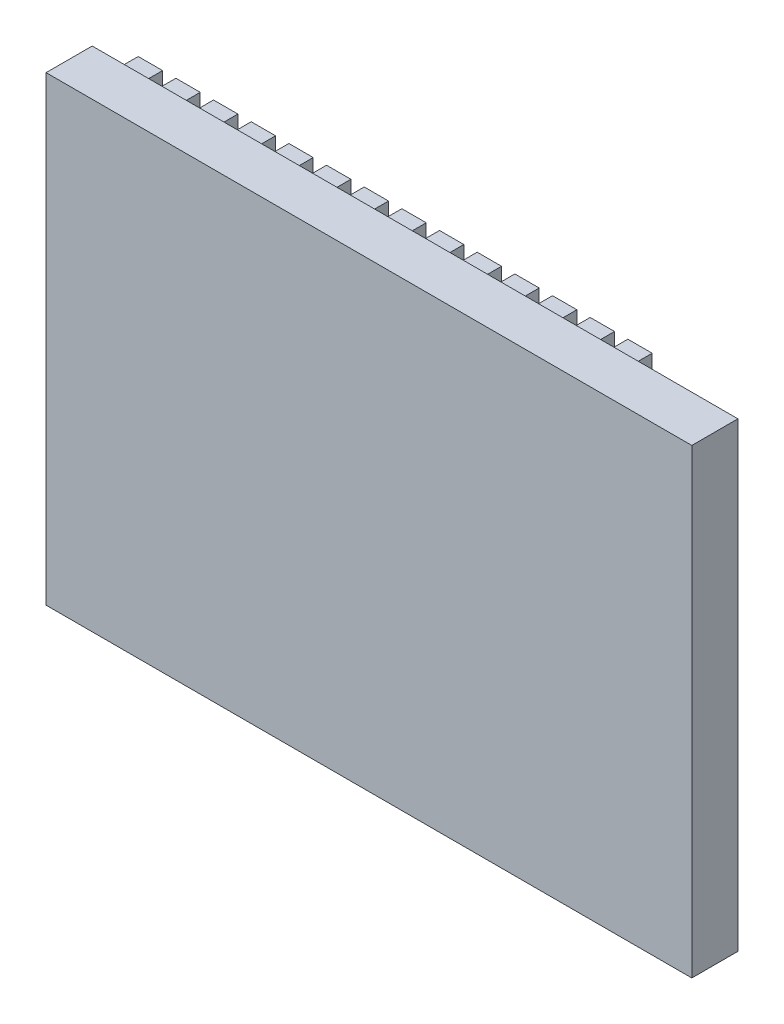
from build123d import *

# Parameters (mm, degrees)
SKETCH1_W           = 70
SKETCH1_H           = 50
BOSS_EXTRUDE1_DEPTH = 5
SKETCH2_W           = 2.640170668
SKETCH2_H           = 2.791037564
SKETCH2_W_2         = 2.640170669
BOSS_EXTRUDE2_DEPTH = 4
SKETCH3_W           = 7.769645109
SKETCH3_H           = 45.109201702
CUT_EXTRUDE2_DEPTH  = 2
SKETCH4_W           = 12.974552998
SKETCH4_H           = 23.007201537
BOSS_EXTRUDE3_DEPTH = 4


with BuildPart() as part:
    # Sketch1 → Boss-Extrude1 (new body)
    with BuildSketch(Plane.XY):
        with Locations((4.17218543, 13.824503311)):
            Rectangle(SKETCH1_W, SKETCH1_H)
    extrude(amount=BOSS_EXTRUDE1_DEPTH)

    # Sketch2 → Boss-Extrude2 (add)
    with BuildSketch(Plane(origin=(0, 0, 0), x_dir=(-1, 0, 0), z_dir=(0, 0, -1))):
        with Locations((-24.557996106, 34.938427472)):
            Rectangle(SKETCH2_W, SKETCH2_H)
        with Locations((-20.475121474, 34.938427472)):
            Rectangle(SKETCH2_W, SKETCH2_H)
        with Locations((-16.392246842, 34.938427472)):
            Rectangle(SKETCH2_W_2, SKETCH2_H)
        with Locations((-12.309372209, 34.938427472)):
            Rectangle(SKETCH2_W, SKETCH2_H)
        with Locations((-8.226497577, 34.938427472)):
            Rectangle(SKETCH2_W, SKETCH2_H)
        with Locations((-4.143622945, 34.938427472)):
            Rectangle(SKETCH2_W_2, SKETCH2_H)
        with Locations((-0.060748312, 34.938427472)):
            Rectangle(SKETCH2_W, SKETCH2_H)
        with Locations((4.02212632, 34.938427472)):
            Rectangle(SKETCH2_W, SKETCH2_H)
        with Locations((8.105000952, 34.938427472)):
            Rectangle(SKETCH2_W, SKETCH2_H)
        with Locations((12.187875585, 34.938427472)):
            Rectangle(SKETCH2_W, SKETCH2_H)
        with Locations((16.270750217, 34.938427472)):
            Rectangle(SKETCH2_W, SKETCH2_H)
        with Locations((20.353624849, 34.938427472)):
            Rectangle(SKETCH2_W, SKETCH2_H)
        with Locations((24.436499482, 34.938427472)):
            Rectangle(SKETCH2_W_2, SKETCH2_H)
        with Locations((28.519374114, 34.938427472)):
            Rectangle(SKETCH2_W, SKETCH2_H)
        with Locations((-25.086447815, -8.058325182)):
            Rectangle(SKETCH2_W, SKETCH2_H)
        with Locations((-21.003573182, -8.058325182)):
            Rectangle(SKETCH2_W, SKETCH2_H)
        with Locations((-16.92069855, -8.058325182)):
            Rectangle(SKETCH2_W, SKETCH2_H)
        with Locations((-12.837823918, -8.058325182)):
            Rectangle(SKETCH2_W, SKETCH2_H)
        with Locations((-8.754949286, -8.058325182)):
            Rectangle(SKETCH2_W_2, SKETCH2_H)
        with Locations((3.493674612, -8.058325182)):
            Rectangle(SKETCH2_W_2, SKETCH2_H)
        with Locations((7.576549244, -8.058325182)):
            Rectangle(SKETCH2_W, SKETCH2_H)
        with Locations((11.659423876, -8.058325182)):
            Rectangle(SKETCH2_W, SKETCH2_H)
        with Locations((15.742298508, -8.058325182)):
            Rectangle(SKETCH2_W, SKETCH2_H)
        with Locations((19.825173141, -8.058325182)):
            Rectangle(SKETCH2_W, SKETCH2_H)
        with Locations((23.908047773, -8.058325182)):
            Rectangle(SKETCH2_W, SKETCH2_H)
        with Locations((27.990922405, -8.058325182)):
            Rectangle(SKETCH2_W, SKETCH2_H)
    extrude(amount=BOSS_EXTRUDE2_DEPTH)

    # Sketch3 → Cut-Extrude2 (cut)
    with BuildSketch(Plane(origin=(0, 0, 0), x_dir=(-1, 0, 0), z_dir=(0, 0, -1))):
        with Locations((-33.251779505, 13.57301761)):
            Rectangle(SKETCH3_W, SKETCH3_H)
    extrude(amount=-CUT_EXTRUDE2_DEPTH, mode=Mode.SUBTRACT)

    # Sketch4 → Boss-Extrude3 (add)
    with BuildSketch(Plane(origin=(0, 0, 0), x_dir=(-1, 0, 0), z_dir=(0, 0, -1))):
        with Locations((16.345712334, 13.899936759)):
            Rectangle(SKETCH4_W, SKETCH4_H)
    extrude(amount=BOSS_EXTRUDE3_DEPTH)


solid = part.part
